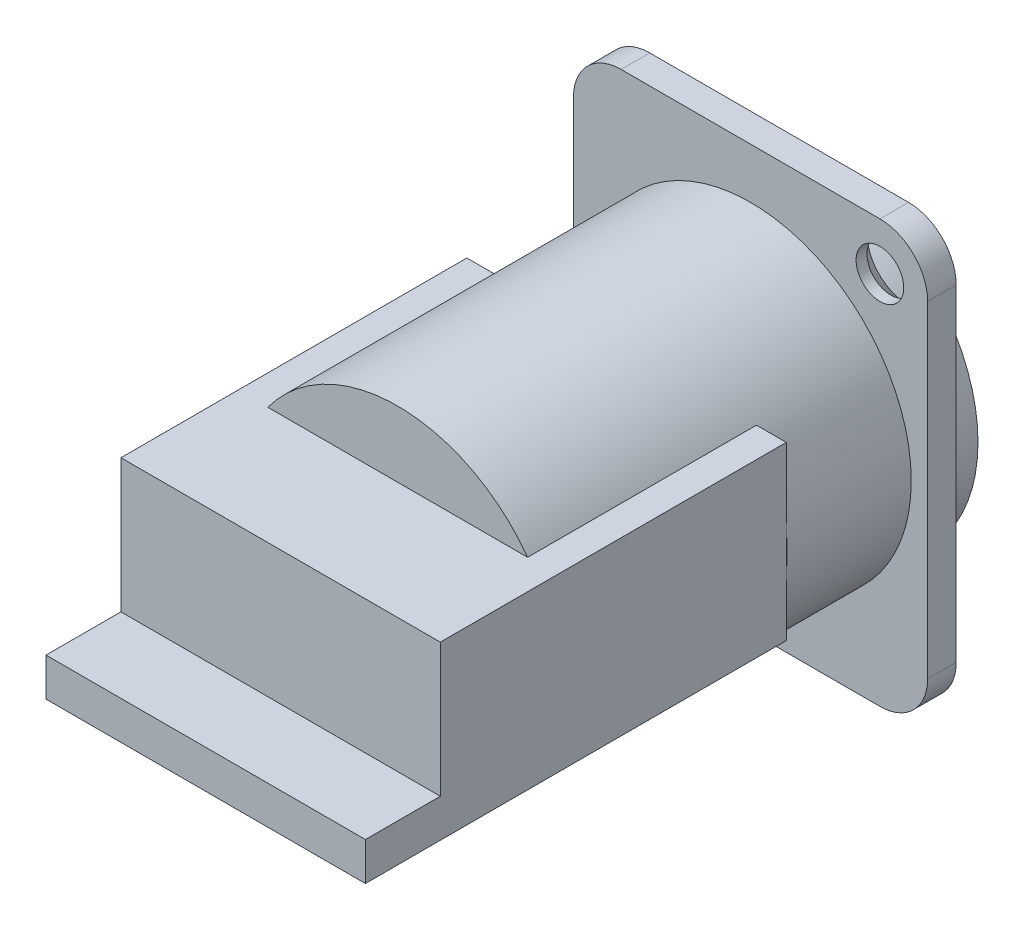
from build123d import *

# Parameters (mm, degrees)
ESQUISSE1_W                                    = 26
ESQUISSE1_H                                    = 27.3
BOSS_EXTRU_1_DEPTH                             = 2.1
ESQUISSE2_R                                    = 11.8
BOSS_EXTRU_2_DEPTH                             = 40
ESQUISSE3_W                                    = 26
ESQUISSE3_H                                    = 2.1
BOSS_EXTRU_3_DEPTH                             = 3.7
ESQUISSE4_R                                    = 11.8
BOSS_EXTRU_4_DEPTH                             = 2.8
D_GAGEMENT_M181_D                              = 20.9
D_GAGEMENT_M181_DEPTH                          = 13.9
ESQUISSE7_R                                    = 8.75
BOSS_EXTRU_5_DEPTH                             = 10.7
ENL_V_MAT_EXTRU_1_DEPTH                        = 10.8
ESQUISSE9_W                                    = 5.1
ESQUISSE9_H                                    = 1.25
ENL_V_MAT_EXTRU_2_DEPTH                        = 0.5
ENL_V_MAT_EXTRU_3_DEPTH                        = 30.9
BOSS_EXTRU_6_DEPTH                             = 30.9
ENL_V_MAT_EXTRU_4_DEPTH                        = 30.9
BOSS_EXTRU_7_DEPTH                             = 30.9
BOSS_EXTRU_8_DEPTH                             = 30.9
BOSS_EXTRU_9_DEPTH                             = 30.9
ENL_V_MAT_EXTRU_5_REACH                        = 16.1
ENL_V_MAT_EXTRU_6_REACH                        = 16.1
ESQUISSE20_W                                   = 5.5
ESQUISSE20_H                                   = 9.8
ENL_V_MAT_EXTRU_7_DEPTH                        = 25.725
BOSS_EXTRU_10_REACH                            = 31.279
ESQUISSE21_W                                   = 1.4
ESQUISSE21_H                                   = 4.4
FRAISAGE_POUR_VIS_T_TE_FRAIS_E_M31_D           = 3.5
FRAISAGE_POUR_VIS_T_TE_FRAIS_E_M31_DEPTH       = 42.1
FRAISAGE_POUR_VIS_T_TE_FRAIS_E_M31_CSINK_D     = 6.099893765
FRAISAGE_POUR_VIS_T_TE_FRAIS_E_M31_CSINK_ANGLE = 89.999002
CONG_1_R                                       = 3.5


with BuildPart() as part:
    # Esquisse1 → Boss.-Extru.1 (new body)
    with BuildSketch(Plane(origin=(0, 0, 0), x_dir=(-1, 0, 0), z_dir=(0, 0, -1))):
        with Locations((0, -1.85)):
            Rectangle(ESQUISSE1_W, ESQUISSE1_H)
    extrude(amount=-BOSS_EXTRU_1_DEPTH)

    # Esquisse2 → Boss.-Extru.2 (add)
    with BuildSketch(Plane.XY.offset(2.1)):
        Circle(ESQUISSE2_R)
    extrude(amount=BOSS_EXTRU_2_DEPTH)

    # Esquisse3 → Boss.-Extru.3 (add)
    with BuildSketch(Plane(origin=(0, 11.8, 0), x_dir=(-1, 0, 0), z_dir=(0, 1, 0))):
        with Locations((0, 1.05)):
            Rectangle(ESQUISSE3_W, ESQUISSE3_H)
    extrude(amount=BOSS_EXTRU_3_DEPTH)

    # Esquisse4 → Boss.-Extru.4 (add)
    with BuildSketch(Plane(origin=(0, 0, 0), x_dir=(-1, 0, 0), z_dir=(0, 0, -1))):
        Circle(ESQUISSE4_R)
    extrude(amount=BOSS_EXTRU_4_DEPTH)

    # Dégagement M181
    with Locations(Plane(origin=(0, 0, -2.8), x_dir=(-1, 0, 0), z_dir=(0, 0, -1))):
        with Locations((0, 0)):
            Hole(D_GAGEMENT_M181_D / 2, depth=D_GAGEMENT_M181_DEPTH)

    # Esquisse7 → Boss.-Extru.5 (add)
    with BuildSketch(Plane(origin=(0, 0, 11.1), x_dir=(-1, 0, 0), z_dir=(0, 0, -1))):
        Circle(ESQUISSE7_R)
    extrude(amount=BOSS_EXTRU_5_DEPTH)

    # Esquisse8 → Enlèv. mat.-Extru.1 (cut)
    with BuildSketch(Plane(origin=(0, 0, 0.4), x_dir=(-1, 0, 0), z_dir=(0, 0, -1))):
        Polygon((6.35, -3.8), (6.35, 3.8), (-6.35, 3.8), (-6.35, -3.8), (-3.65, -3.8), (-3.65, -5.6), (-2.55, -5.6), (-2.55, -6.9), (2.55, -6.9), (2.55, -5.6), (3.65, -5.6), (3.65, -3.8), align=None)
    extrude(amount=-ENL_V_MAT_EXTRU_1_DEPTH, mode=Mode.SUBTRACT)

    # Esquisse9 → Enlèv. mat.-Extru.2 (cut)
    with BuildSketch(Plane(origin=(0, 0, 11.2), x_dir=(-1, 0, 0), z_dir=(0, 0, -1))):
        with Locations((0, -6.275)):
            Rectangle(ESQUISSE9_W, ESQUISSE9_H)
    extrude(amount=-ENL_V_MAT_EXTRU_2_DEPTH, mode=Mode.SUBTRACT)

    # Esquisse10 → Enlèv. mat.-Extru.3 (cut)
    with BuildSketch(Plane.XY.offset(42.1)):
        with BuildLine():
            Line((-11.725, -1.328297783), (-11.725, 1.328297783))
            ThreePointArc((-11.725, 1.328297783), (-11.8, 0), (-11.725, -1.328297783))
        make_face()
    extrude(amount=-ENL_V_MAT_EXTRU_3_DEPTH, mode=Mode.SUBTRACT)

    # Esquisse11 → Boss.-Extru.6 (add)
    with BuildSketch(Plane.XY.offset(42.1)):
        with BuildLine():
            Line((-9.536115561, 6.95), (-11.725, 6.95))
            Line((-11.725, 6.95), (-11.725, 1.328297783))
            ThreePointArc((-11.725, 1.328297783), (-10.995892082, 4.281396655), (-9.536115561, 6.95))
        make_face()
    extrude(amount=-BOSS_EXTRU_6_DEPTH)

    # Esquisse12 → Enlèv. mat.-Extru.4 (cut)
    with BuildSketch(Plane.XY.offset(42.1)):
        with BuildLine():
            Line((11.725, 1.328297783), (11.725, -1.328297783))
            ThreePointArc((11.725, -1.328297783), (11.8, 0), (11.725, 1.328297783))
        make_face()
    extrude(amount=-ENL_V_MAT_EXTRU_4_DEPTH, mode=Mode.SUBTRACT)

    # Esquisse13 → Boss.-Extru.7 (add)
    with BuildSketch(Plane.XY.offset(42.1)):
        with BuildLine():
            Line((11.725, 1.328297783), (11.725, 6.95))
            Line((11.725, 6.95), (9.536115561, 6.95))
            ThreePointArc((9.536115561, 6.95), (10.995892082, 4.281396655), (11.725, 1.328297783))
        make_face()
    extrude(amount=-BOSS_EXTRU_7_DEPTH)

    # Esquisse14 → Boss.-Extru.8 (add)
    with BuildSketch(Plane.XY.offset(42.1)):
        with BuildLine():
            Line((-11.725, -1.328297783), (-11.725, -5.65))
            Line((-11.725, -5.65), (-10.359416007, -5.65))
            ThreePointArc((-10.359416007, -5.65), (-11.251650328, -3.555329084), (-11.725, -1.328297783))
        make_face()
    extrude(amount=-BOSS_EXTRU_8_DEPTH)

    # Esquisse15 → Boss.-Extru.9 (add)
    with BuildSketch(Plane.XY.offset(42.1)):
        with BuildLine():
            Line((10.359416007, -5.65), (11.725, -5.65))
            Line((11.725, -5.65), (11.725, -1.328297783))
            ThreePointArc((11.725, -1.328297783), (11.251650328, -3.555329084), (10.359416007, -5.65))
        make_face()
    extrude(amount=-BOSS_EXTRU_9_DEPTH)

    # Esquisse17 → Enlèv. mat.-Extru.5 (cut, up to next)
    with BuildSketch(Plane(origin=(0, 0, 28), x_dir=(-1, 0, 0), z_dir=(0, 0, -1)), mode=Mode.PRIVATE) as enl_v_mat_extru_5_sk1:
        with BuildLine():
            Line((-9.536115561, 6.95), (9.536115561, 6.95))
            ThreePointArc((9.536115561, 6.95), (0, 11.8), (-9.536115561, 6.95))
        make_face()
    enl_v_mat_extru_5_tool1 = extrude(enl_v_mat_extru_5_sk1.sketch, amount=-ENL_V_MAT_EXTRU_5_REACH, mode=Mode.PRIVATE) & part.part
    add(enl_v_mat_extru_5_tool1.solids().sort_by_distance((0, 8.928831, 28))[0], mode=Mode.SUBTRACT)

    # Esquisse19 → Enlèv. mat.-Extru.6 (cut, up to next)
    with BuildSketch(Plane(origin=(0, 0, 28), x_dir=(-1, 0, 0), z_dir=(0, 0, -1)), mode=Mode.PRIVATE) as enl_v_mat_extru_6_sk1:
        with BuildLine():
            Line((10.359416007, -5.65), (-10.359416007, -5.65))
            ThreePointArc((-10.359416007, -5.65), (0, -11.8), (10.359416007, -5.65))
        make_face()
    enl_v_mat_extru_6_tool1 = extrude(enl_v_mat_extru_6_sk1.sketch, amount=-ENL_V_MAT_EXTRU_6_REACH, mode=Mode.PRIVATE) & part.part
    add(enl_v_mat_extru_6_tool1.solids().sort_by_distance((0, -8.174843, 28))[0], mode=Mode.SUBTRACT)

    # Esquisse20 → Enlèv. mat.-Extru.7 (cut, through all)
    with BuildSketch(Plane.ZY.offset(11.725)):
        with Locations((39.35, 2.05)):
            Rectangle(ESQUISSE20_W, ESQUISSE20_H)
    extrude(amount=-ENL_V_MAT_EXTRU_7_DEPTH, mode=Mode.SUBTRACT)

    # Esquisse21 → Boss.-Extru.10 (add, up to next)
    with BuildSketch(Plane.XZ.offset(13.779218989), mode=Mode.PRIVATE) as boss_extru_10_sk1:
        with Locations((0, 25.8)):
            Rectangle(ESQUISSE21_W, ESQUISSE21_H)
    boss_extru_10_tool1 = extrude(boss_extru_10_sk1.sketch, amount=-BOSS_EXTRU_10_REACH, mode=Mode.PRIVATE) - part.part
    add(boss_extru_10_tool1.solids().sort_by_distance((0, -13.779219, 25.8))[0])

    # Fraisage pour vis à tête fraisée M31
    with Locations(Plane(origin=(0, 0, 0), x_dir=(-1, 0, 0), z_dir=(0, 0, -1))):
        with Locations((-9.5, 12), (9.5, -12)):
            CounterSinkHole(FRAISAGE_POUR_VIS_T_TE_FRAIS_E_M31_D / 2, FRAISAGE_POUR_VIS_T_TE_FRAIS_E_M31_CSINK_D / 2, depth=FRAISAGE_POUR_VIS_T_TE_FRAIS_E_M31_DEPTH, counter_sink_angle=FRAISAGE_POUR_VIS_T_TE_FRAIS_E_M31_CSINK_ANGLE)

    # Congé1
    cong_1_edges = [part.edges().sort_by_distance(p)[0] for p in [
        (13, 15.5, 1.05),
        (-13, 15.5, 1.05),
        (-13, -15.5, 1.05),
        (13, -15.5, 1.05),
    ]]
    fillet(cong_1_edges, radius=CONG_1_R)


solid = part.part
